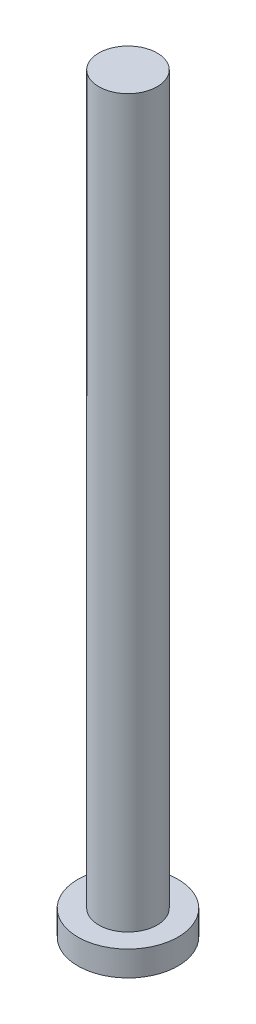
from build123d import *


with BuildPart() as part:
    # Çizim1 → Döndür1 (revolve)
    with BuildSketch(Plane.XY):
        Polygon((6, 90), (6, 0), (12, 0), (12, 3), (9.5, 3), (9.5, 90), align=None)
    revolve(axis=Axis((6, 90, 0), (0, -1, 0)))


solid = part.part
